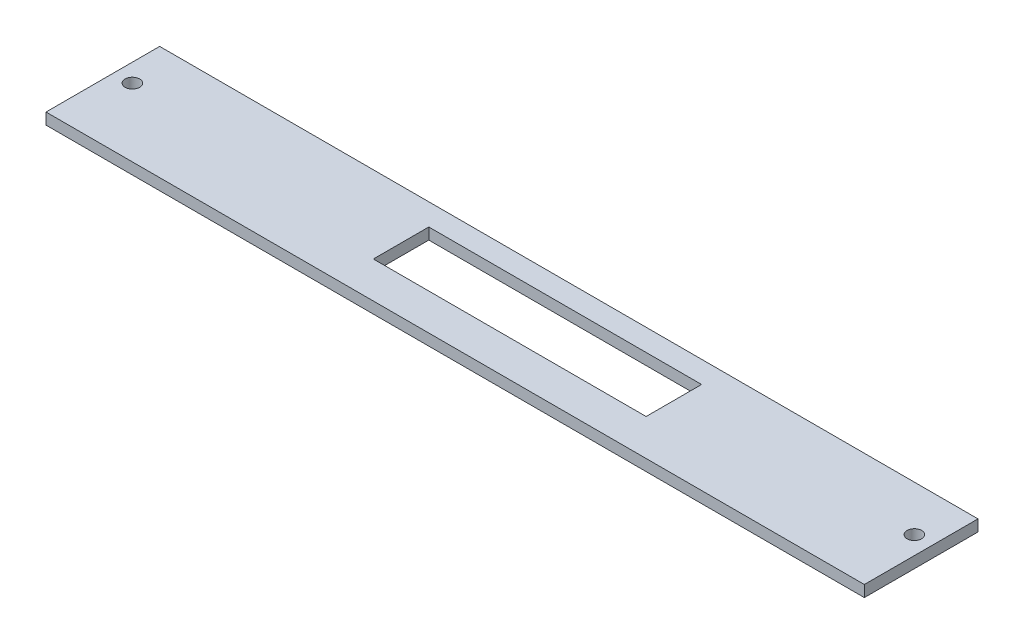
from build123d import *

# Parameters (mm, degrees)
SKETCH1_W           = 228.6
SKETCH1_H           = 31.75
BOSS_EXTRUDE1_DEPTH = 3.175
SKETCH2_R           = 2.032
CUT_EXTRUDE1_DEPTH  = 3.175
SKETCH3_W           = 76.2
SKETCH3_H           = 15.494
CUT_EXTRUDE2_DEPTH  = 3.175


with BuildPart() as part:
    # Sketch1 → Boss-Extrude1 (new body)
    with BuildSketch(Plane(origin=(0, 0, 0), x_dir=(1, 0, 0), z_dir=(0, 1, 0))):
        with Locations((114.3, 15.875)):
            Rectangle(SKETCH1_W, SKETCH1_H)
    extrude(amount=BOSS_EXTRUDE1_DEPTH)

    # Sketch2 → Cut-Extrude1 (cut)
    with BuildSketch(Plane(origin=(0, 3.175, 0), x_dir=(1, 0, 0), z_dir=(0, 1, 0))):
        with Locations((5.08, 19.05)):
            Circle(SKETCH2_R)
        with Locations((223.52, 19.05)):
            Circle(SKETCH2_R)
    extrude(amount=-CUT_EXTRUDE1_DEPTH, mode=Mode.SUBTRACT)

    # Sketch3 → Cut-Extrude2 (cut)
    with BuildSketch(Plane(origin=(0, 3.175, 0), x_dir=(1, 0, 0), z_dir=(0, 1, 0))):
        with Locations((119.38, 17.907)):
            Rectangle(SKETCH3_W, SKETCH3_H)
    extrude(amount=-CUT_EXTRUDE2_DEPTH, mode=Mode.SUBTRACT)


solid = part.part
